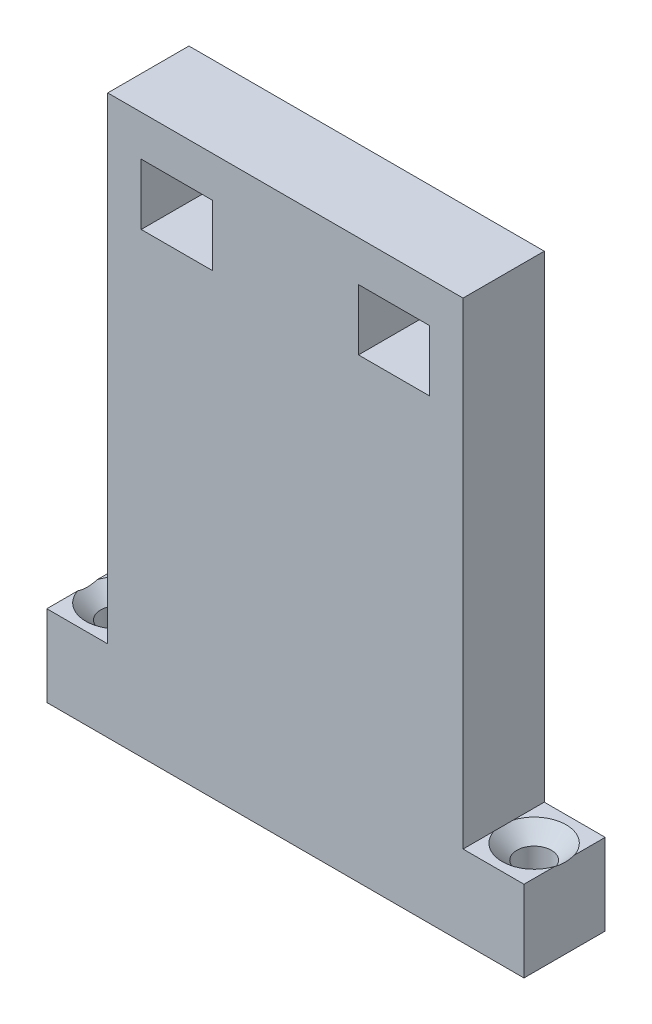
from build123d import *

# Parameters (mm, degrees)
SKETCH2_W                                      = 7
SKETCH2_H                                      = 6
BOSS_EXTRUDE1_DEPTH                            = 8
CSK_FOR_M3_FLAT_HEAD_MACHINE_SCREW1_AT_2_COUNT = 2
CSK_FOR_M3_FLAT_HEAD_MACHINE_SCREW1_AT_2_PITCH = 41


with BuildPart() as part:
    # Sketch2 → Boss-Extrude1 (new body)
    with BuildSketch(Plane.XY):
        Polygon((23.5, 0), (-23.5, 0), (-23.5, 8), (-17.5, 8), (-17.5, 55), (17.5, 55), (17.5, 8), (23.5, 8), align=None)
        with Locations((10.7, 48)):
            Rectangle(SKETCH2_W, SKETCH2_H, mode=Mode.SUBTRACT)
        with Locations((-10.7, 48)):
            Rectangle(SKETCH2_W, SKETCH2_H, mode=Mode.SUBTRACT)
    extrude(amount=BOSS_EXTRUDE1_DEPTH)

    # Sketch4 → CSK for M3 Flat Head Machine Screw1 (revolve, cut)
    with BuildSketch(Plane(origin=(-20.5, 8, 4), x_dir=(0, 0, 1), z_dir=(1, 0, 0))):
        Polygon((0, 0), (0, 8), (1.7, 8), (1.7, 1.45), (3.15, 0), align=None)
    csk_for_m3_flat_head_machine_screw1 = revolve(axis=Axis((-20.5, 14.35, 4), (0, -1, 0)), mode=Mode.SUBTRACT)

    # CSK for M3 Flat Head Machine Screw1 at 2: CSK for M3 Flat Head Machine Screw1 ×2
    with Locations(*[(i * CSK_FOR_M3_FLAT_HEAD_MACHINE_SCREW1_AT_2_PITCH, 0, 0) for i in range(1, CSK_FOR_M3_FLAT_HEAD_MACHINE_SCREW1_AT_2_COUNT)]):
        add(csk_for_m3_flat_head_machine_screw1, mode=Mode.SUBTRACT)


solid = part.part
